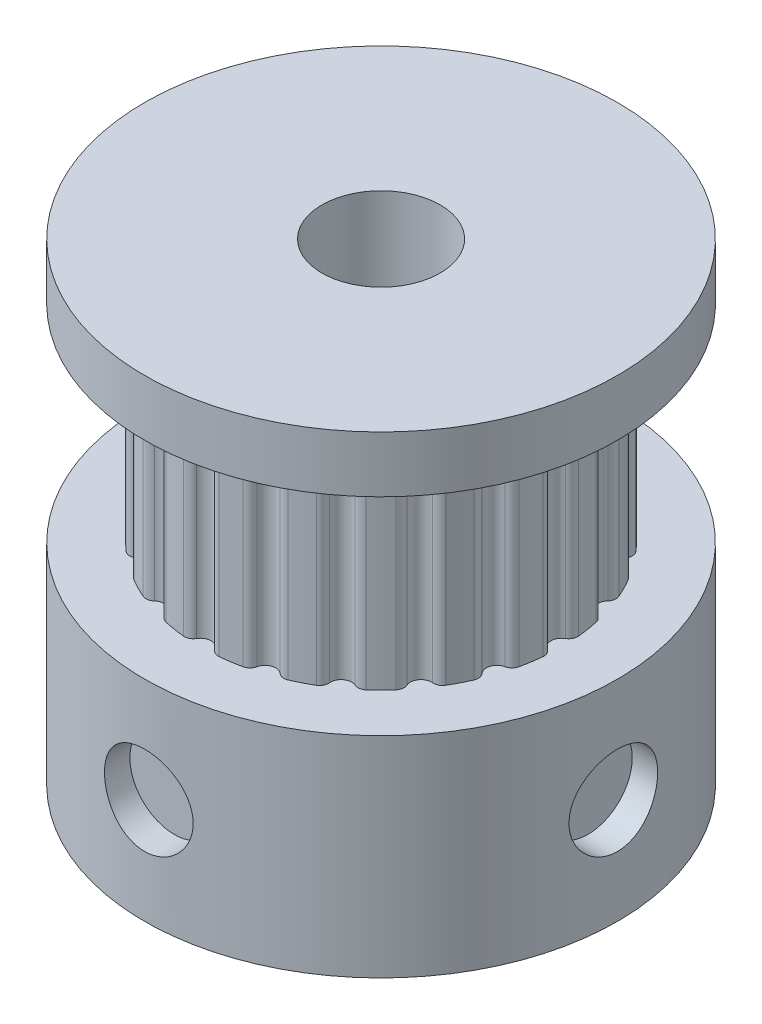
from build123d import *

# Parameters (mm, degrees)
CUT_EXTRUDE1_DEPTH = 7
SKETCH4_R          = 1.5
CUT_EXTRUDE2_DEPTH = 1
CIRPATTERN1_COUNT  = 4


with BuildPart() as part:
    # Sketch2 → Revolve1 (revolve)
    with BuildSketch(Plane.XY):
        Polygon((2, 8.9), (8, 8.9), (8, 7), (6.11, 7), (6.11, 0), (8, 0), (8, -7.1), (2, -7.1), align=None)
    revolve(axis=Axis((0, -8, 0), (0, 1, 0)))

    # Sketch3 → Cut-Extrude1 (cut)
    with BuildSketch(Plane.XZ.offset(-7)):
        with BuildLine():
            ThreePointArc((-0.311769145, 5.93), (-0.18, 5.798230855), (0, 5.75))
            ThreePointArc((0, 5.75), (0.18, 5.798230855), (0.311769145, 5.93))
            ThreePointArc((0.311769145, 5.93), (0.435881591, 6.048113073), (0.604210181, 6.080051814))
            ThreePointArc((0.604210181, 6.080051814), (0, 6.11), (-0.604210181, 6.080051814))
            ThreePointArc((-0.604210181, 6.080051814), (-0.435881591, 6.048113073), (-0.311769145, 5.93))
        make_face()
        with BuildLine():
            ThreePointArc((1.535960699, 5.736107106), (1.620561702, 5.570068292), (1.776847728, 5.468574965))
            ThreePointArc((1.776847728, 5.468574965), (1.962942049, 5.458822179), (2.128980854, 5.543423177))
            ThreePointArc((2.128980854, 5.543423177), (2.283517751, 5.61740253), (2.453477367, 5.595761683))
            ThreePointArc((2.453477367, 5.595761683), (1.888093836, 5.810955315), (1.304201308, 5.969184111))
            ThreePointArc((1.304201308, 5.969184111), (1.454421696, 5.886792168), (1.535960699, 5.736107106))
        make_face()
        with BuildLine():
            ThreePointArc((3.737793083, 4.614217471), (3.907627283, 4.636821489), (4.062581094, 4.563719411))
            ThreePointArc((4.062581094, 4.563719411), (3.591367892, 4.943093836), (3.084948485, 5.274011077))
            ThreePointArc((3.084948485, 5.274011077), (3.202356053, 5.149231031), (3.233340009, 4.980724082))
            ThreePointArc((3.233340009, 4.980724082), (3.262491526, 4.796668645), (3.379765199, 4.651847719))
            ThreePointArc((3.379765199, 4.651847719), (3.553737644, 4.585065953), (3.737793083, 4.614217471))
        make_face()
        with BuildLine():
            ThreePointArc((4.980724082, 3.233340009), (5.149231031, 3.202356053), (5.274011077, 3.084948485))
            ThreePointArc((5.274011077, 3.084948485), (4.943093836, 3.591367892), (4.563719411, 4.062581094))
            ThreePointArc((4.563719411, 4.062581094), (4.636821489, 3.907627283), (4.614217471, 3.737793083))
            ThreePointArc((4.614217471, 3.737793083), (4.585065953, 3.553737644), (4.651847719, 3.379765199))
            ThreePointArc((4.651847719, 3.379765199), (4.796668645, 3.262491526), (4.980724082, 3.233340009))
        make_face()
        with BuildLine():
            ThreePointArc((5.736107106, 1.535960699), (5.886792168, 1.454421696), (5.969184111, 1.304201308))
            ThreePointArc((5.969184111, 1.304201308), (5.810955315, 1.888093836), (5.595761683, 2.453477367))
            ThreePointArc((5.595761683, 2.453477367), (5.61740253, 2.283517751), (5.543423177, 2.128980854))
            ThreePointArc((5.543423177, 2.128980854), (5.458822178, 1.962942044), (5.468574969, 1.776847716))
            ThreePointArc((5.468574969, 1.776847716), (5.570068297, 1.620561698), (5.736107106, 1.535960699))
        make_face()
        with BuildLine():
            ThreePointArc((6.080051814, -0.604210181), (6.102508361, -0.302475964), (6.11, 0))
            ThreePointArc((6.11, 0), (6.102508361, 0.302475964), (6.080051814, 0.604210181))
            ThreePointArc((6.080051814, 0.604210181), (6.048113073, 0.435881591), (5.93, 0.311769145))
            ThreePointArc((5.93, 0.311769145), (5.798230855, 0.18), (5.75, 0))
            ThreePointArc((5.75, 0), (5.798230855, -0.18), (5.93, -0.311769145))
            ThreePointArc((5.93, -0.311769145), (6.048113073, -0.435881591), (6.080051814, -0.604210181))
        make_face()
        with BuildLine():
            ThreePointArc((5.595761683, -2.453477367), (5.810955315, -1.888093836), (5.969184111, -1.304201308))
            ThreePointArc((5.969184111, -1.304201308), (5.886792168, -1.454421696), (5.736107106, -1.535960699))
            ThreePointArc((5.736107106, -1.535960699), (5.570068292, -1.620561702), (5.468574965, -1.776847728))
            ThreePointArc((5.468574965, -1.776847728), (5.458822179, -1.962942049), (5.543423177, -2.128980854))
            ThreePointArc((5.543423177, -2.128980854), (5.61740253, -2.283517751), (5.595761683, -2.453477367))
        make_face()
        with BuildLine():
            ThreePointArc((4.563719411, -4.062581094), (4.943093836, -3.591367892), (5.274011077, -3.084948485))
            ThreePointArc((5.274011077, -3.084948485), (5.149231031, -3.202356053), (4.980724082, -3.233340009))
            ThreePointArc((4.980724082, -3.233340009), (4.796668645, -3.262491526), (4.651847719, -3.379765199))
            ThreePointArc((4.651847719, -3.379765199), (4.585065953, -3.553737644), (4.614217471, -3.737793083))
            ThreePointArc((4.614217471, -3.737793083), (4.636821489, -3.907627283), (4.563719411, -4.062581094))
        make_face()
        with BuildLine():
            ThreePointArc((3.737793083, -4.614217471), (3.553737644, -4.585065953), (3.379765199, -4.651847719))
            ThreePointArc((3.379765199, -4.651847719), (3.262491526, -4.796668645), (3.233340009, -4.980724082))
            ThreePointArc((3.233340009, -4.980724082), (3.202356053, -5.149231031), (3.084948485, -5.274011077))
            ThreePointArc((3.084948485, -5.274011077), (3.591367892, -4.943093836), (4.062581094, -4.563719411))
            ThreePointArc((4.062581094, -4.563719411), (3.907627283, -4.636821489), (3.737793083, -4.614217471))
        make_face()
        with BuildLine():
            ThreePointArc((2.128980854, -5.543423177), (1.962942035, -5.458822176), (1.7768477, -5.468574974))
            ThreePointArc((1.7768477, -5.468574974), (1.620561692, -5.570068303), (1.535960699, -5.736107106))
            ThreePointArc((1.535960699, -5.736107106), (1.454421696, -5.886792168), (1.304201308, -5.969184111))
            ThreePointArc((1.304201308, -5.969184111), (1.888093836, -5.810955315), (2.453477367, -5.595761683))
            ThreePointArc((2.453477367, -5.595761683), (2.283517751, -5.61740253), (2.128980854, -5.543423177))
        make_face()
        with BuildLine():
            ThreePointArc((0.311769145, -5.93), (0.18, -5.798230855), (0, -5.75))
            ThreePointArc((0, -5.75), (-0.18, -5.798230855), (-0.311769145, -5.93))
            ThreePointArc((-0.311769145, -5.93), (-0.435881591, -6.048113073), (-0.604210181, -6.080051814))
            ThreePointArc((-0.604210181, -6.080051814), (0, -6.11), (0.604210181, -6.080051814))
            ThreePointArc((0.604210181, -6.080051814), (0.435881591, -6.048113073), (0.311769145, -5.93))
        make_face()
        with BuildLine():
            ThreePointArc((-1.535960699, -5.736107106), (-1.620561844, -5.570068135), (-1.776848131, -5.468574834))
            ThreePointArc((-1.776848131, -5.468574834), (-1.962942257, -5.458822223), (-2.128980854, -5.543423177))
            ThreePointArc((-2.128980854, -5.543423177), (-2.283517751, -5.61740253), (-2.453477367, -5.595761683))
            ThreePointArc((-2.453477367, -5.595761683), (-1.888093836, -5.810955315), (-1.304201308, -5.969184111))
            ThreePointArc((-1.304201308, -5.969184111), (-1.454421696, -5.886792168), (-1.535960699, -5.736107106))
        make_face()
        with BuildLine():
            ThreePointArc((-3.233340009, -4.980724082), (-3.262491637, -4.796668398), (-3.379765637, -4.6518474))
            ThreePointArc((-3.379765637, -4.6518474), (-3.553737913, -4.585065925), (-3.737793083, -4.614217471))
            ThreePointArc((-3.737793083, -4.614217471), (-3.907627283, -4.636821489), (-4.062581094, -4.563719411))
            ThreePointArc((-4.062581094, -4.563719411), (-3.591367892, -4.943093836), (-3.084948485, -5.274011077))
            ThreePointArc((-3.084948485, -5.274011077), (-3.202356053, -5.149231031), (-3.233340009, -4.980724082))
        make_face()
        with BuildLine():
            ThreePointArc((-4.614217471, -3.737793083), (-4.585065985, -3.553737342), (-4.651848075, -3.379764708))
            ThreePointArc((-4.651848075, -3.379764708), (-4.796668922, -3.262491403), (-4.980724082, -3.233340009))
            ThreePointArc((-4.980724082, -3.233340009), (-5.149231031, -3.202356053), (-5.274011077, -3.084948485))
            ThreePointArc((-5.274011077, -3.084948485), (-4.943093836, -3.591367892), (-4.563719411, -4.062581094))
            ThreePointArc((-4.563719411, -4.062581094), (-4.636821489, -3.907627283), (-4.614217471, -3.737793083))
        make_face()
        with BuildLine():
            ThreePointArc((-5.543423177, -2.128980854), (-5.458822245, -1.962942359), (-5.46857477, -1.77684833))
            ThreePointArc((-5.46857477, -1.77684833), (-5.570068057, -1.620561914), (-5.736107106, -1.535960699))
            ThreePointArc((-5.736107106, -1.535960699), (-5.886792168, -1.454421696), (-5.969184111, -1.304201308))
            ThreePointArc((-5.969184111, -1.304201308), (-5.810955315, -1.888093836), (-5.595761683, -2.453477367))
            ThreePointArc((-5.595761683, -2.453477367), (-5.61740253, -2.283517751), (-5.543423177, -2.128980854))
        make_face()
        with BuildLine():
            ThreePointArc((-5.93, -0.311769145), (-5.798230855, -0.18), (-5.75, 0))
            ThreePointArc((-5.75, 0), (-5.798230855, 0.18), (-5.93, 0.311769145))
            ThreePointArc((-5.93, 0.311769145), (-6.048113073, 0.435881591), (-6.080051814, 0.604210181))
            ThreePointArc((-6.080051814, 0.604210181), (-6.11, 0), (-6.080051814, -0.604210181))
            ThreePointArc((-6.080051814, -0.604210181), (-6.048113073, -0.435881591), (-5.93, -0.311769145))
        make_face()
        with BuildLine():
            ThreePointArc((-5.736107106, 1.535960699), (-5.570068064, 1.620561908), (-5.468574775, 1.776848313))
            ThreePointArc((-5.468574775, 1.776848313), (-5.458822243, 1.962942351), (-5.543423177, 2.128980854))
            ThreePointArc((-5.543423177, 2.128980854), (-5.61740253, 2.283517751), (-5.595761683, 2.453477367))
            ThreePointArc((-5.595761683, 2.453477367), (-5.810955315, 1.888093836), (-5.969184111, 1.304201308))
            ThreePointArc((-5.969184111, 1.304201308), (-5.886792168, 1.454421696), (-5.736107106, 1.535960699))
        make_face()
        with BuildLine():
            ThreePointArc((-3.737793083, 4.614217471), (-3.553737886, 4.585065928), (-3.379765593, 4.651847433))
            ThreePointArc((-3.379765593, 4.651847433), (-3.262491625, 4.796668423), (-3.233340009, 4.980724082))
            ThreePointArc((-3.233340009, 4.980724082), (-3.202356053, 5.149231031), (-3.084948485, 5.274011077))
            ThreePointArc((-3.084948485, 5.274011077), (-3.591367892, 4.943093836), (-4.062581094, 4.563719411))
            ThreePointArc((-4.062581094, 4.563719411), (-3.907627283, 4.636821489), (-3.737793083, 4.614217471))
        make_face()
        with BuildLine():
            ThreePointArc((-2.128980854, 5.543423177), (-1.962942215, 5.458822215), (-1.77684805, 5.468574861))
            ThreePointArc((-1.77684805, 5.468574861), (-1.620561815, 5.570068167), (-1.535960699, 5.736107106))
            ThreePointArc((-1.535960699, 5.736107106), (-1.454421696, 5.886792168), (-1.304201308, 5.969184111))
            ThreePointArc((-1.304201308, 5.969184111), (-1.888093836, 5.810955315), (-2.453477367, 5.595761683))
            ThreePointArc((-2.453477367, 5.595761683), (-2.283517751, 5.61740253), (-2.128980854, 5.543423177))
        make_face()
        with BuildLine():
            ThreePointArc((-4.980724082, 3.233340009), (-4.796668383, 3.262491643), (-4.651847381, 3.379765663))
            ThreePointArc((-4.651847381, 3.379765663), (-4.585065923, 3.553737929), (-4.614217471, 3.737793083))
            ThreePointArc((-4.614217471, 3.737793083), (-4.636821489, 3.907627283), (-4.563719411, 4.062581094))
            ThreePointArc((-4.563719411, 4.062581094), (-4.943093836, 3.591367892), (-5.274011077, 3.084948485))
            ThreePointArc((-5.274011077, 3.084948485), (-5.149231031, 3.202356053), (-4.980724082, 3.233340009))
        make_face()
    extrude(amount=CUT_EXTRUDE1_DEPTH, mode=Mode.SUBTRACT)

    # Sketch4 → Cut-Extrude2 (cut)
    with BuildSketch(Plane.ZY.offset(8)):
        with Locations((0, -3.55)):
            Circle(SKETCH4_R)
    cut_extrude2 = extrude(amount=-CUT_EXTRUDE2_DEPTH, mode=Mode.SUBTRACT)

    # CirPattern1: Cut-Extrude2 ×4 about axis
    cirpattern1_axis = Axis((0, 0, 0), (0, 1, 0))
    for i in range(1, CIRPATTERN1_COUNT):
        add(cut_extrude2.rotate(cirpattern1_axis, i * 360 / CIRPATTERN1_COUNT), mode=Mode.SUBTRACT)


solid = part.part
